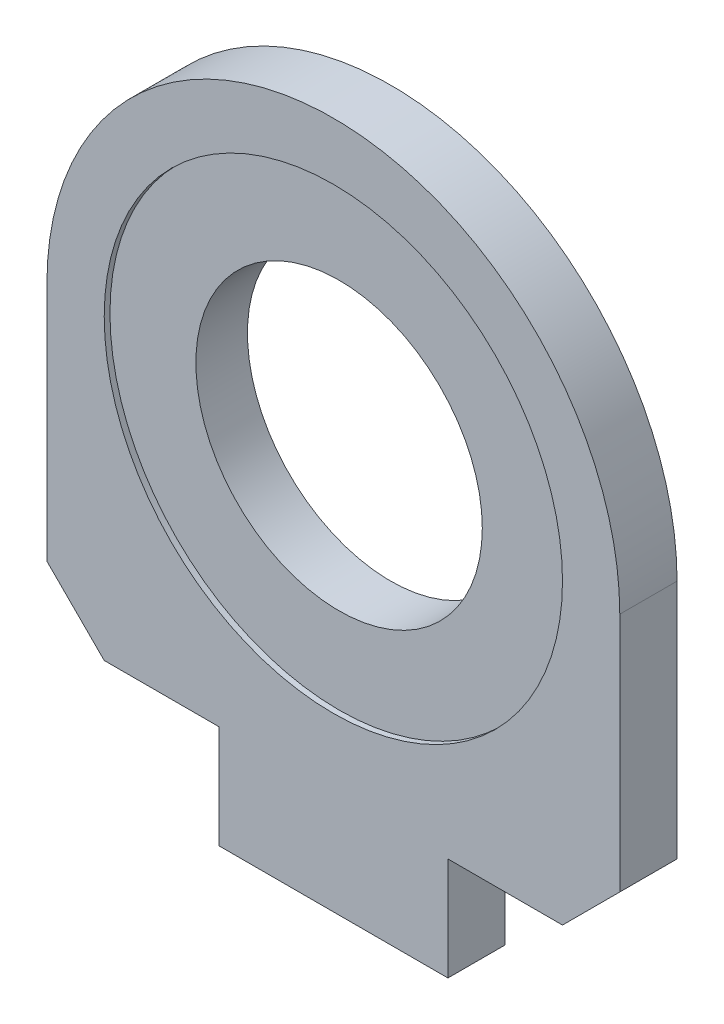
from build123d import *

# Parameters (mm, degrees)
SKETCH_1_R          = 25
EXTRUDE_1_DEPTH     = 10
CUT_EXTRUDE_START   = 10
SKETCH_1_4_R        = 40
CUT_EXTRUDE_1_DEPTH = 1


with BuildPart() as part:
    # 草圖1 → 填料-伸長1 (new body)
    with BuildSketch(Plane.XY):
        with BuildLine():
            Line((-50, 0), (-50, -42))
            Line((-50, -42), (-40, -52))
            Line((-40, -52), (-20, -52))
            Line((-20, -52), (-20, -70))
            Line((-20, -70), (20, -70))
            Line((20, -70), (20, -52))
            Line((20, -52), (40, -52))
            Line((40, -52), (50, -42))
            Line((50, -42), (50, 0))
            ThreePointArc((50, 0), (0, 50), (-50, 0))
        make_face()
        Circle(SKETCH_1_R, mode=Mode.SUBTRACT)
    extrude(amount=EXTRUDE_1_DEPTH)

    # 草圖1<4> → 除料-伸長1 (cut)
    with BuildSketch(Plane.XY.offset(CUT_EXTRUDE_START)):
        Circle(SKETCH_1_4_R)
    extrude(amount=-CUT_EXTRUDE_1_DEPTH, mode=Mode.SUBTRACT)


solid = part.part
